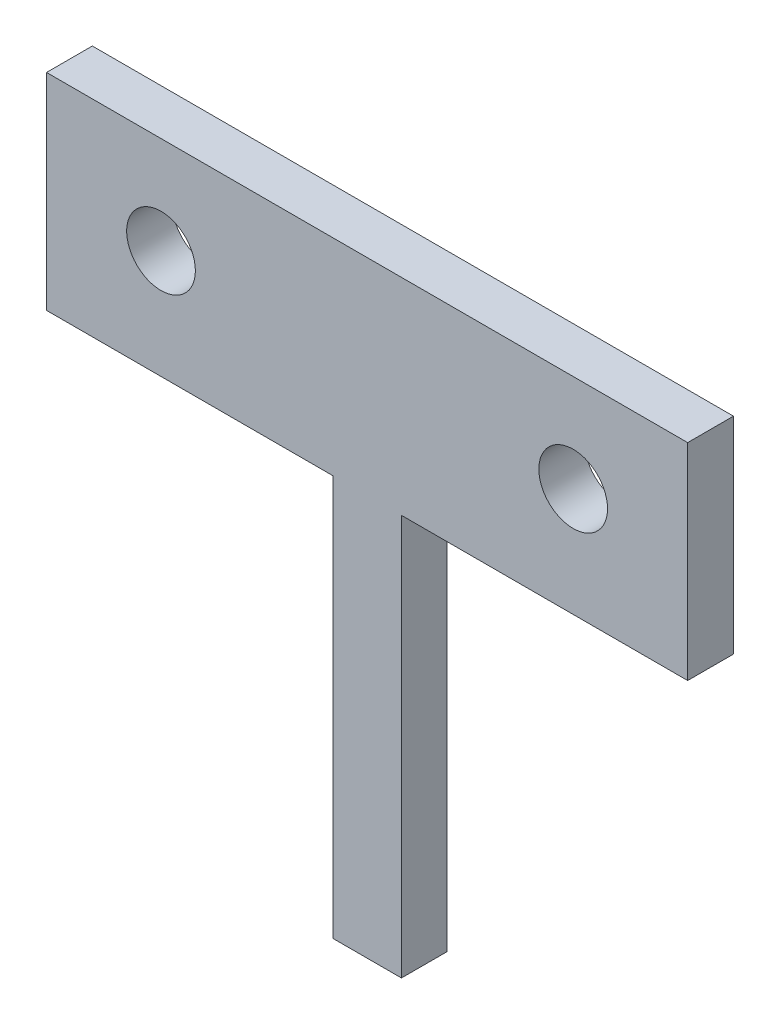
from build123d import *

# Parameters (mm, degrees)
SKETCH1_W           = 28
SKETCH1_H           = 9
SKETCH1_R           = 1.5
SKETCH1_W_2         = 3
SKETCH1_H_2         = 17.5
BOSS_EXTRUDE1_DEPTH = 2


with BuildPart() as part:
    # Sketch1 → Boss-Extrude1 (new body)
    with BuildSketch(Plane.XY):
        with Locations((14, 4.5)):
            Rectangle(SKETCH1_W, SKETCH1_H)
        with Locations((5, 4.75)):
            Circle(SKETCH1_R, mode=Mode.SUBTRACT)
        with Locations((23, 4.75)):
            Circle(SKETCH1_R, mode=Mode.SUBTRACT)
        with Locations((14, -8.75)):
            Rectangle(SKETCH1_W_2, SKETCH1_H_2)
    extrude(amount=BOSS_EXTRUDE1_DEPTH)


solid = part.part
